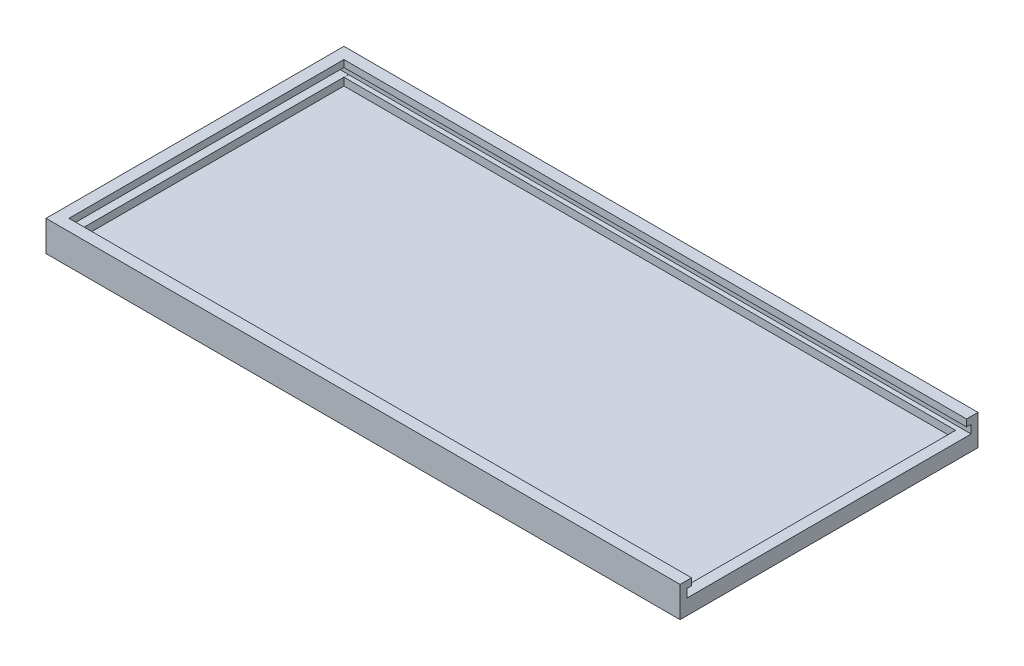
from build123d import *

# Parameters (mm, degrees)
SKETCH_1_W            = 166
SKETCH_1_H            = 78
EXTRUDE_293_DEPTH     = 8
SKETCH_2_W            = 163
SKETCH_2_H            = 72
CUT_EXTRUDE_531_DEPTH = 6
SKETCH_7_W            = 163
SKETCH_7_H            = 2.2
CUT_EXTRUDE_3_DEPTH   = 1.2
SKETCH_8_W            = 75.4
SKETCH_8_H            = 2.189311695
CUT_EXTRUDE_4_DEPTH   = 2.2
SKETCH_9_W            = 163
SKETCH_9_H            = 2.2
CUT_EXTRUDE_5_DEPTH   = 1.2
SKETCH_10_W           = 2.869065247
SKETCH_10_H           = 72
EXTRUDE_1_DEPTH       = 2


with BuildPart() as part:
    # Эскиз1 → Extrude 293 (new body)
    with BuildSketch(Plane(origin=(0, 0, 0), x_dir=(1, 0, 0), z_dir=(0, 1, 0))):
        with Locations((83, 39)):
            Rectangle(SKETCH_1_W, SKETCH_1_H)
    extrude(amount=EXTRUDE_293_DEPTH)

    # Эскиз2 → Cut-Extrude 531 (cut)
    with BuildSketch(Plane(origin=(0, 8, 0), x_dir=(1, 0, 0), z_dir=(0, 1, 0))):
        with Locations((84.5, 39)):
            Rectangle(SKETCH_2_W, SKETCH_2_H)
    extrude(amount=-CUT_EXTRUDE_531_DEPTH, mode=Mode.SUBTRACT)

    # Эскиз7 → Вырез-Вытянуть3 (cut)
    with BuildSketch(Plane.XY.offset(-75)):
        with Locations((84.5, 5.1)):
            Rectangle(SKETCH_7_W, SKETCH_7_H)
    extrude(amount=-CUT_EXTRUDE_3_DEPTH, mode=Mode.SUBTRACT)

    # Эскиз8 → Вырез-Вытянуть4 (cut)
    with BuildSketch(Plane(origin=(3, 0, 0), x_dir=(0, 0, -1), z_dir=(1, 0, 0))):
        with Locations((38.5, 5.105344153)):
            Rectangle(SKETCH_8_W, SKETCH_8_H)
    extrude(amount=-CUT_EXTRUDE_4_DEPTH, mode=Mode.SUBTRACT)

    # Эскиз9 → Вырез-Вытянуть5 (cut)
    with BuildSketch(Plane(origin=(0, 0, -3), x_dir=(-1, 0, 0), z_dir=(0, 0, -1))):
        with Locations((-84.5, 5.1)):
            Rectangle(SKETCH_9_W, SKETCH_9_H)
    extrude(amount=-CUT_EXTRUDE_5_DEPTH, mode=Mode.SUBTRACT)

    # Эскиз10 → Бобышка-Вытянуть1 (add)
    with BuildSketch(Plane(origin=(0, 2, 0), x_dir=(1, 0, 0), z_dir=(0, 1, 0))):
        with Locations((164.565467377, 39)):
            Rectangle(SKETCH_10_W, SKETCH_10_H)
    extrude(amount=EXTRUDE_1_DEPTH)


solid = part.part
